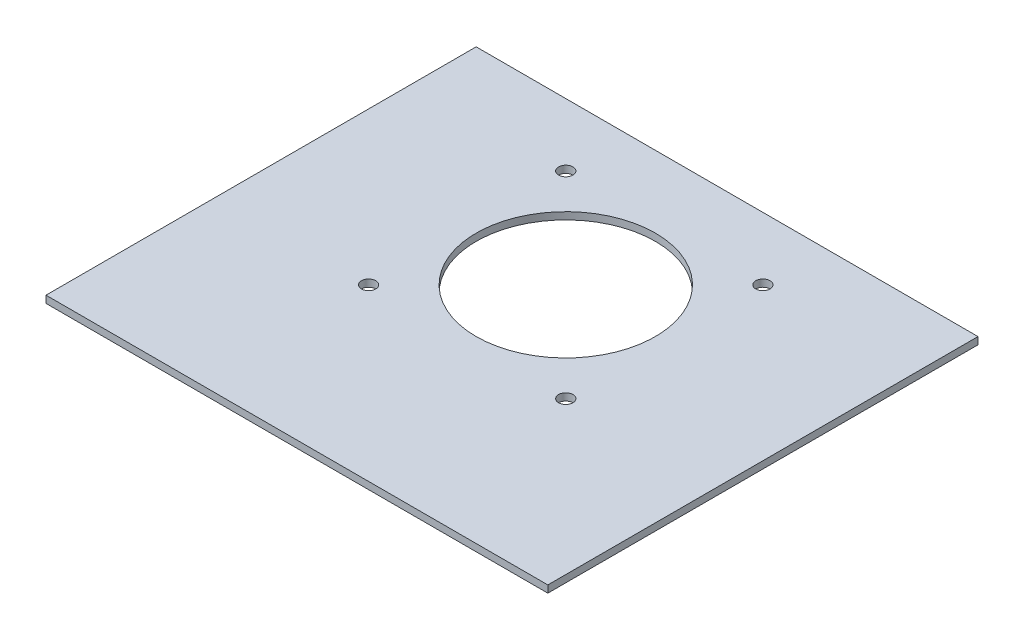
from build123d import *

# Parameters (mm, degrees)
SKETCH_1_W      = 140
SKETCH_1_H      = 120
SKETCH_1_R      = 2
SKETCH_1_R_2    = 25
EXTRUDE_1_DEPTH = 2


with BuildPart() as part:
    # Эскиз1 → Бобышка-Вытянуть1 (new body)
    with BuildSketch(Plane(origin=(0, 0, 0), x_dir=(1, 0, 0), z_dir=(0, 1, 0))):
        with Locations((0, -15)):
            Rectangle(SKETCH_1_W, SKETCH_1_H)
        with Locations((27.5, 27.5)):
            Circle(SKETCH_1_R, mode=Mode.SUBTRACT)
        with Locations((-27.5, 27.5)):
            Circle(SKETCH_1_R, mode=Mode.SUBTRACT)
        with Locations((-27.5, -27.5)):
            Circle(SKETCH_1_R, mode=Mode.SUBTRACT)
        with Locations((27.5, -27.5)):
            Circle(SKETCH_1_R, mode=Mode.SUBTRACT)
        Circle(SKETCH_1_R_2, mode=Mode.SUBTRACT)
    extrude(amount=EXTRUDE_1_DEPTH)


solid = part.part
